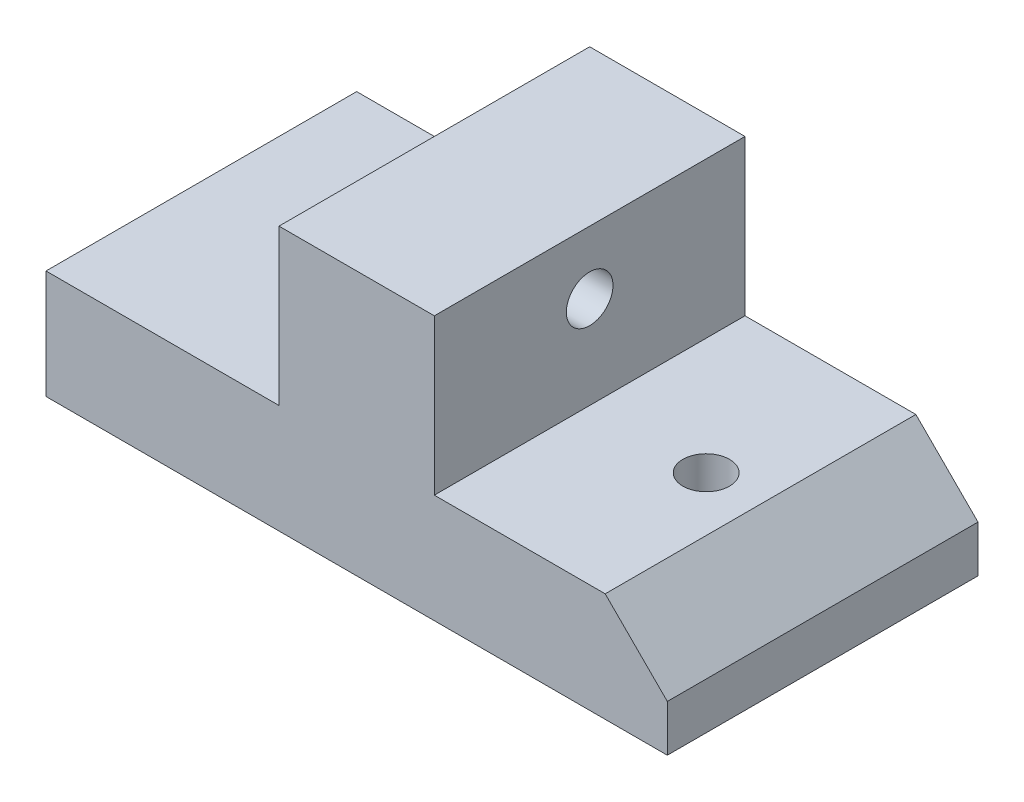
from build123d import *

# Parameters (mm, degrees)
SKETCH1_W               = 40
SKETCH1_H               = 20
BOSS_EXTRUDE1_DEPTH     = 4
SKETCH2_W               = 10
SKETCH2_H               = 20
BOSS_EXTRUDE2_DEPTH     = 10
SKETCH3_R               = 1.5
CUT_EXTRUDE1_DEPTH      = 20
SKETCH4_R               = 1.5
CUT_EXTRUDE2_DEPTH      = 20
CUT_EXTRUDE3_DEPTH      = 43.242250662
CUT_EXTRUDE3_DEPTH_BACK = 20
SKETCH6_W               = 40
SKETCH6_H               = 20
BOSS_EXTRUDE3_DEPTH     = 4.5
CUT_EXTRUDE5_DEPTH      = 4.5
CUT_EXTRUDE6_DEPTH      = 14.5
SKETCH9_W               = 40
SKETCH9_H               = 20
CUT_EXTRUDE7_DEPTH      = 1.5


with BuildPart() as part:
    # Sketch1 → Boss-Extrude1 (new body)
    with BuildSketch(Plane(origin=(0, 0, 0), x_dir=(1, 0, 0), z_dir=(0, 1, 0))):
        with Locations((-14.473290255, 1.083337988)):
            Rectangle(SKETCH1_W, SKETCH1_H)
    extrude(amount=BOSS_EXTRUDE1_DEPTH)

    # Sketch2 → Boss-Extrude2 (add)
    with BuildSketch(Plane(origin=(0, 4, 0), x_dir=(1, 0, 0), z_dir=(0, 1, 0))):
        with Locations((-14.473290255, 1.083337988)):
            Rectangle(SKETCH2_W, SKETCH2_H)
    extrude(amount=BOSS_EXTRUDE2_DEPTH)

    # Sketch3 → Cut-Extrude1 (cut)
    with BuildSketch(Plane(origin=(-9.473290255, 0, 0), x_dir=(0, 0, -1), z_dir=(1, 0, 0))):
        with Locations((1.083337988, 9.951)):
            Circle(SKETCH3_R)
    extrude(amount=-CUT_EXTRUDE1_DEPTH, mode=Mode.SUBTRACT)

    # Sketch4 → Cut-Extrude2 (cut)
    with BuildSketch(Plane(origin=(0, 4, 0), x_dir=(1, 0, 0), z_dir=(0, 1, 0))):
        with BuildLine():
            ThreePointArc((-1.073290255, 2.283337988), (-3.173290255, 1.983337988), (-2.873290255, -0.116662012))
            Line((-2.873290255, -0.116662012), (-1.073290255, 2.283337988))
        make_face()
        with BuildLine():
            Line((-1.073290255, 2.283337988), (-2.873290255, -0.116662012))
            ThreePointArc((-2.873290255, -0.116662012), (-1.302469862, -0.258302799), (-0.473290255, 1.083337988))
            ThreePointArc((-0.473290255, 1.083337988), (-0.631649468, 1.754158381), (-1.073290255, 2.283337988))
        make_face()
        with Locations(Location((-26.973290255, 1.083337988, 0), (0, 0, 270))):
            Circle(SKETCH4_R)
    extrude(amount=-CUT_EXTRUDE2_DEPTH, mode=Mode.SUBTRACT)

    # Sketch5 → Cut-Extrude3 (cut, two sides)
    with BuildSketch(Plane.XY.offset(8.916662012)) as cut_extrude3_sk:
        Polygon((100.285190147, 4), (5.526709745, 4), (1.526709745, 4), (5.526709745, 0), (72.531073812, -67.004364067), (249.0428395, -135.999110287), (276.796955834, -64.99474622), align=None)
    extrude(amount=CUT_EXTRUDE3_DEPTH, mode=Mode.SUBTRACT)
    extrude(cut_extrude3_sk.sketch, amount=-CUT_EXTRUDE3_DEPTH_BACK, mode=Mode.SUBTRACT)

    # Sketch6 → Boss-Extrude3 (add)
    with BuildSketch(Plane.XZ):
        with Locations((-14.473290255, -1.083337988)):
            Rectangle(SKETCH6_W, SKETCH6_H)
    extrude(amount=BOSS_EXTRUDE3_DEPTH)

    # Sketch7 → Cut-Extrude5 (cut)
    with BuildSketch(Plane(origin=(0, 0, 0), x_dir=(1, 0, 0), z_dir=(0, 1, 0))):
        with BuildLine():
            ThreePointArc((-0.473290255, 1.083337988), (-1.973290255, 2.583337988), (-3.473290255, 1.083337988))
            Line((-3.473290255, 1.083337988), (-0.473290255, 1.083337988))
        make_face()
        with BuildLine():
            Line((-0.473290255, 1.083337988), (-3.473290255, 1.083337988))
            ThreePointArc((-3.473290255, 1.083337988), (-1.973290255, -0.416662012), (-0.473290255, 1.083337988))
        make_face()
    extrude(amount=-CUT_EXTRUDE5_DEPTH, mode=Mode.SUBTRACT)

    # Sketch8 → Cut-Extrude6 (cut)
    with BuildSketch(Plane(origin=(0, 4, 0), x_dir=(1, 0, 0), z_dir=(0, 1, 0))):
        with BuildLine():
            ThreePointArc((-25.473290255, 1.083337988), (-26.973290255, 2.583337988), (-28.473290255, 1.083337988))
            Line((-28.473290255, 1.083337988), (-25.473290255, 1.083337988))
        make_face()
        with BuildLine():
            Line((-25.473290255, 1.083337988), (-28.473290255, 1.083337988))
            ThreePointArc((-28.473290255, 1.083337988), (-26.973290255, -0.416662012), (-25.473290255, 1.083337988))
        make_face()
    extrude(amount=-CUT_EXTRUDE6_DEPTH, mode=Mode.SUBTRACT)

    # Sketch9 → Cut-Extrude7 (cut)
    with BuildSketch(Plane(origin=(0, -4.5, 0), x_dir=(-1, 0, 0), z_dir=(0, -1, 0))):
        with Locations((14.473290255, 1.083337988)):
            Rectangle(SKETCH9_W, SKETCH9_H)
    extrude(amount=-CUT_EXTRUDE7_DEPTH, mode=Mode.SUBTRACT)


solid = part.part
